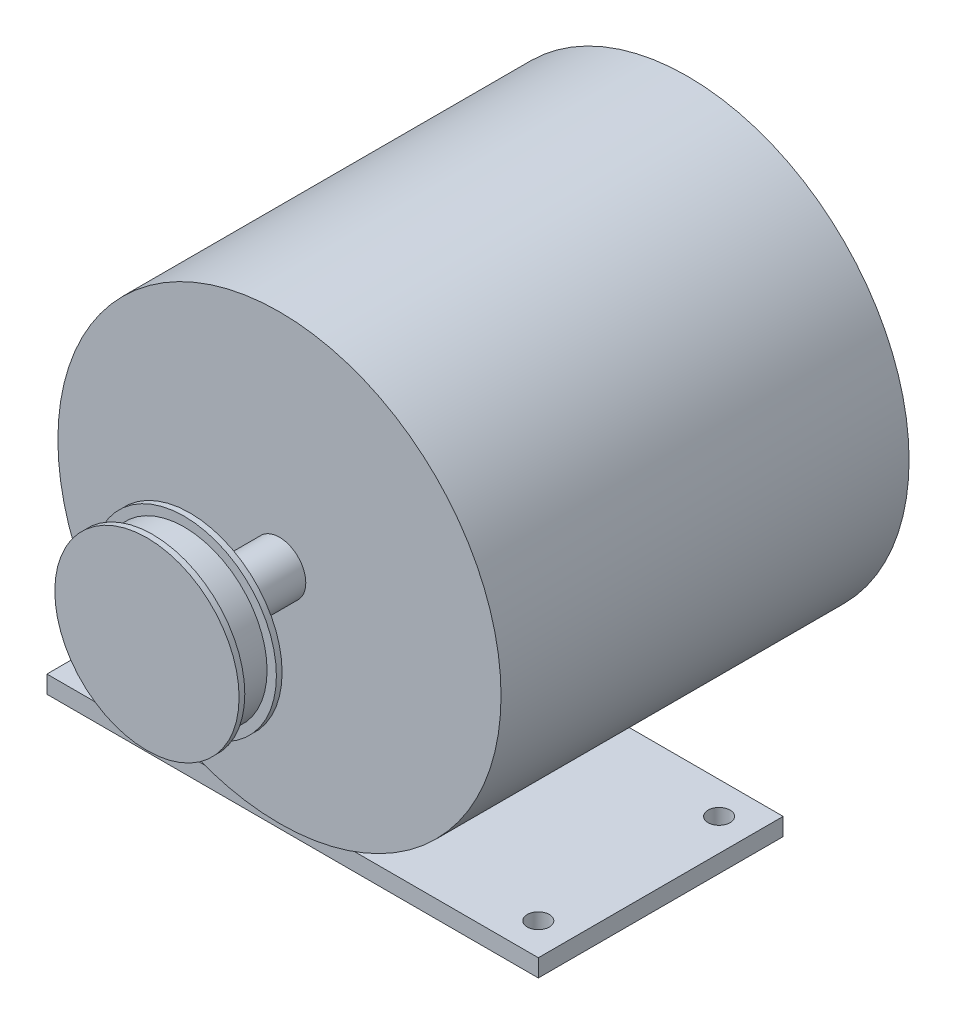
from build123d import *

# Parameters (mm, degrees)
SKETCH1_R           = 50.5
BOSS_EXTRUDE1_DEPTH = 93
SKETCH2_R           = 6
BOSS_EXTRUDE2_DEPTH = 30.2
SKETCH3_R           = 21
BOSS_EXTRUDE3_DEPTH = 1.3
SKETCH4_R           = 18.875
BOSS_EXTRUDE4_DEPTH = 7.2
SKETCH5_R           = 21
BOSS_EXTRUDE5_DEPTH = 1.3
SKETCH6_R           = 12.5
BOSS_EXTRUDE6_DEPTH = 5.6
SKETCH9_W           = 112
SKETCH9_H           = 55.8
BOSS_EXTRUDE7_DEPTH = 4
SKETCH10_R          = 2.5
CUT_EXTRUDE1_DEPTH  = 4


with BuildPart() as part:
    # Sketch1 → Boss-Extrude1 (new body)
    with BuildSketch(Plane.XY):
        Circle(SKETCH1_R)
    extrude(amount=BOSS_EXTRUDE1_DEPTH)

    # Sketch2 → Boss-Extrude2 (add)
    with BuildSketch(Plane.XY.offset(93)):
        Circle(SKETCH2_R)
    extrude(amount=BOSS_EXTRUDE2_DEPTH)

    # Sketch3 → Boss-Extrude3 (add)
    with BuildSketch(Plane.XY.offset(123.2)):
        Circle(SKETCH3_R)
    extrude(amount=-BOSS_EXTRUDE3_DEPTH)

    # Sketch4 → Boss-Extrude4 (add)
    with BuildSketch(Plane(origin=(0, 0, 121.9), x_dir=(-1, 0, 0), z_dir=(0, 0, -1))):
        Circle(SKETCH4_R)
    extrude(amount=BOSS_EXTRUDE4_DEPTH)

    # Sketch5 → Boss-Extrude5 (add)
    with BuildSketch(Plane(origin=(0, 0, 114.7), x_dir=(-1, 0, 0), z_dir=(0, 0, -1))):
        Circle(SKETCH5_R)
    extrude(amount=BOSS_EXTRUDE5_DEPTH)

    # Sketch6 → Boss-Extrude6 (add)
    with BuildSketch(Plane(origin=(0, 0, 113.4), x_dir=(-1, 0, 0), z_dir=(0, 0, -1))):
        Circle(SKETCH6_R)
    extrude(amount=BOSS_EXTRUDE6_DEPTH)


with BuildPart() as body_2:
    # Sketch9 → Boss-Extrude7 (new body)
    with BuildSketch(Plane(origin=(0, -54.5, 0), x_dir=(1, 0, 0), z_dir=(0, 1, 0))):
        with Locations((0, -62.1)):
            Rectangle(SKETCH9_W, SKETCH9_H)
    extrude(amount=BOSS_EXTRUDE7_DEPTH)

    # Sketch10 → Cut-Extrude1 (cut)
    with BuildSketch(Plane.XZ.offset(54.5)):
        with Locations((48.7, 82.7)):
            Circle(SKETCH10_R)
        with Locations((48.7, 41.5)):
            Circle(SKETCH10_R)
        with Locations((-48.7, 82.7)):
            Circle(SKETCH10_R)
        with Locations((-48.7, 41.5)):
            Circle(SKETCH10_R)
    extrude(amount=-CUT_EXTRUDE1_DEPTH, mode=Mode.SUBTRACT)


solid = Compound([part.part, body_2.part])
